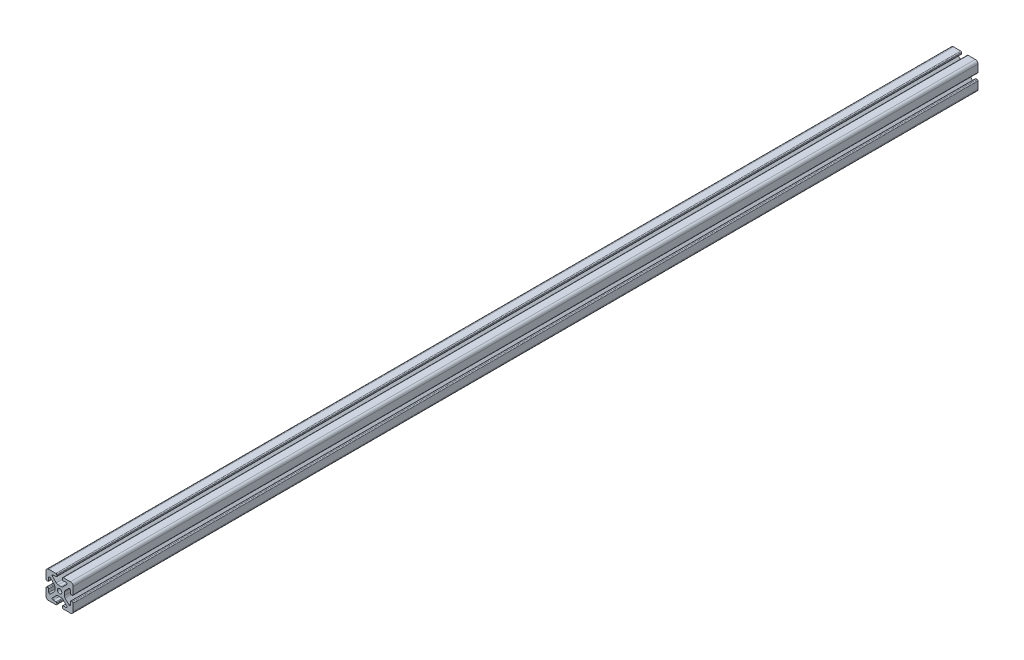
from build123d import *

# Parameters (mm, degrees)
SKETCH1_R           = 2.5
BOSS_EXTRUDE1_DEPTH = 1000


with BuildPart() as part:
    # Sketch1 → Boss-Extrude1 (new body)
    with BuildSketch(Plane.XY):
        with BuildLine():
            Line((1.603196264, 5.250000001), (-1.603196256, 5.250000001))
            ThreePointArc((-1.603196256, 5.250000001), (-2.751246551, 5.478361403), (-3.724516596, 6.128679656))
            Line((-3.724516596, 6.128679656), (-7.850557356, 10.254720416))
            ThreePointArc((-7.850557356, 10.254720416), (-8.072177387, 11.368879549), (-7.127638883, 12))
            Line((-7.127638883, 12), (-3.899999993, 12))
            ThreePointArc((-3.899999993, 12), (-3.334314568, 12.234314575), (-3.099999993, 12.8))
            Line((-3.099999993, 12.8), (-3.099999993, 14))
            ThreePointArc((-3.099999993, 14), (-3.392893211, 14.707106781), (-4.099999993, 15))
            Line((-4.099999993, 15), (-11.999999993, 15))
            ThreePointArc((-11.999999993, 15), (-14.121320336, 14.121320343), (-14.999999993, 12))
            Line((-14.999999993, 12), (-14.999999993, 4.1))
            ThreePointArc((-14.999999993, 4.1), (-14.707106774, 3.392893219), (-13.999999993, 3.1))
            Line((-13.999999993, 3.1), (-12.799999993, 3.1))
            ThreePointArc((-12.799999993, 3.1), (-12.234314568, 3.334314575), (-11.999999993, 3.9))
            Line((-11.999999993, 3.9), (-11.999999993, 7.12763889))
            ThreePointArc((-11.999999993, 7.12763889), (-11.368879545, 8.072177389), (-10.254720418, 7.85055736))
            Line((-10.254720418, 7.85055736), (-6.128679658, 3.7245166))
            ThreePointArc((-6.128679658, 3.7245166), (-5.478361404, 2.751246553), (-5.250000001, 1.603196256))
            Line((-5.250000001, 1.603196256), (-5.250000001, -1.603196264))
            ThreePointArc((-5.250000001, -1.603196264), (-5.478361403, -2.751246559), (-6.128679656, -3.724516604))
            Line((-6.128679656, -3.724516604), (-10.254720416, -7.850557364))
            ThreePointArc((-10.254720416, -7.850557364), (-11.368879549, -8.072177394), (-12, -7.12763889))
            Line((-12, -7.12763889), (-12, -3.9))
            ThreePointArc((-12, -3.9), (-12.234314575, -3.334314575), (-12.8, -3.1))
            Line((-12.8, -3.1), (-14, -3.1))
            ThreePointArc((-14, -3.1), (-14.707106781, -3.392893219), (-15, -4.1))
            Line((-15, -4.1), (-15, -12))
            ThreePointArc((-15, -12), (-14.121320344, -14.121320344), (-12, -15))
            Line((-12, -15), (-4.1, -15))
            ThreePointArc((-4.1, -15), (-3.392893219, -14.707106781), (-3.1, -14))
            Line((-3.1, -14), (-3.1, -12.8))
            ThreePointArc((-3.1, -12.8), (-3.334314575, -12.234314575), (-3.9, -12))
            Line((-3.9, -12), (-7.12763889, -12))
            ThreePointArc((-7.12763889, -12), (-8.07217739, -11.368879552), (-7.85055736, -10.254720425))
            Line((-7.85055736, -10.254720425), (-3.7245166, -6.128679665))
            ThreePointArc((-3.7245166, -6.128679665), (-2.751246554, -5.478361411), (-1.603196256, -5.250000009))
            Line((-1.603196256, -5.250000009), (1.603196264, -5.250000009))
            ThreePointArc((1.603196264, -5.250000009), (2.751246559, -5.478361411), (3.724516604, -6.128679664))
            Line((3.724516604, -6.128679664), (7.850557364, -10.254720424))
            ThreePointArc((7.850557364, -10.254720424), (8.072177394, -11.368879556), (7.12763889, -12.000000007))
            Line((7.12763889, -12.000000007), (3.9, -12.000000007))
            ThreePointArc((3.9, -12.000000007), (3.334314575, -12.234314583), (3.1, -12.800000007))
            Line((3.1, -12.800000007), (3.1, -14.000000007))
            ThreePointArc((3.1, -14.000000007), (3.392893219, -14.707106789), (4.1, -15.000000007))
            Line((4.1, -15.000000007), (12, -15.000000007))
            ThreePointArc((12, -15.000000007), (14.121320343, -14.121320351), (15, -12.000000007))
            Line((15, -12.000000007), (15, -4.100000007))
            ThreePointArc((15, -4.100000007), (14.707106781, -3.392893226), (14, -3.100000007))
            Line((14, -3.100000007), (12.8, -3.100000007))
            ThreePointArc((12.8, -3.100000007), (12.234314575, -3.334314583), (12, -3.900000007))
            Line((12, -3.900000007), (12, -7.127638897))
            ThreePointArc((12, -7.127638897), (11.368879552, -8.072177397), (10.254720425, -7.850557367))
            Line((10.254720425, -7.850557367), (6.128679665, -3.724516607))
            ThreePointArc((6.128679665, -3.724516607), (5.478361411, -2.751246561), (5.250000009, -1.603196264))
            Line((5.250000009, -1.603196264), (5.250000009, 1.603196256))
            ThreePointArc((5.250000009, 1.603196256), (5.478361411, 2.751246551), (6.128679664, 3.724516596))
            Line((6.128679664, 3.724516596), (10.254720424, 7.850557356))
            ThreePointArc((10.254720424, 7.850557356), (11.368879556, 8.072177387), (12.000000007, 7.127638882))
            Line((12.000000007, 7.127638882), (12.000000007, 3.899999992))
            ThreePointArc((12.000000007, 3.899999992), (12.234314582, 3.334314567), (12.800000007, 3.099999992))
            Line((12.800000007, 3.099999992), (14.000000007, 3.099999992))
            ThreePointArc((14.000000007, 3.099999992), (14.707106788, 3.392893211), (15.000000007, 4.099999992))
            Line((15.000000007, 4.099999992), (15.000000007, 11.999999992))
            ThreePointArc((15.000000007, 11.999999992), (14.121320351, 14.121320336), (12.000000007, 14.999999992))
            Line((12.000000007, 14.999999992), (4.100000007, 14.999999992))
            ThreePointArc((4.100000007, 14.999999992), (3.392893226, 14.707106774), (3.100000007, 13.999999992))
            Line((3.100000007, 13.999999992), (3.100000007, 12.799999992))
            ThreePointArc((3.100000007, 12.799999992), (3.334314582, 12.234314567), (3.900000007, 11.999999992))
            Line((3.900000007, 11.999999992), (7.127638897, 11.999999992))
            ThreePointArc((7.127638897, 11.999999992), (8.072177397, 11.368879544), (7.850557367, 10.254720418))
            Line((7.850557367, 10.254720418), (3.724516607, 6.128679658))
            ThreePointArc((3.724516607, 6.128679658), (2.751246561, 5.478361404), (1.603196264, 5.250000001))
        make_face()
        Circle(SKETCH1_R, mode=Mode.SUBTRACT)
    extrude(amount=BOSS_EXTRUDE1_DEPTH)


solid = part.part
